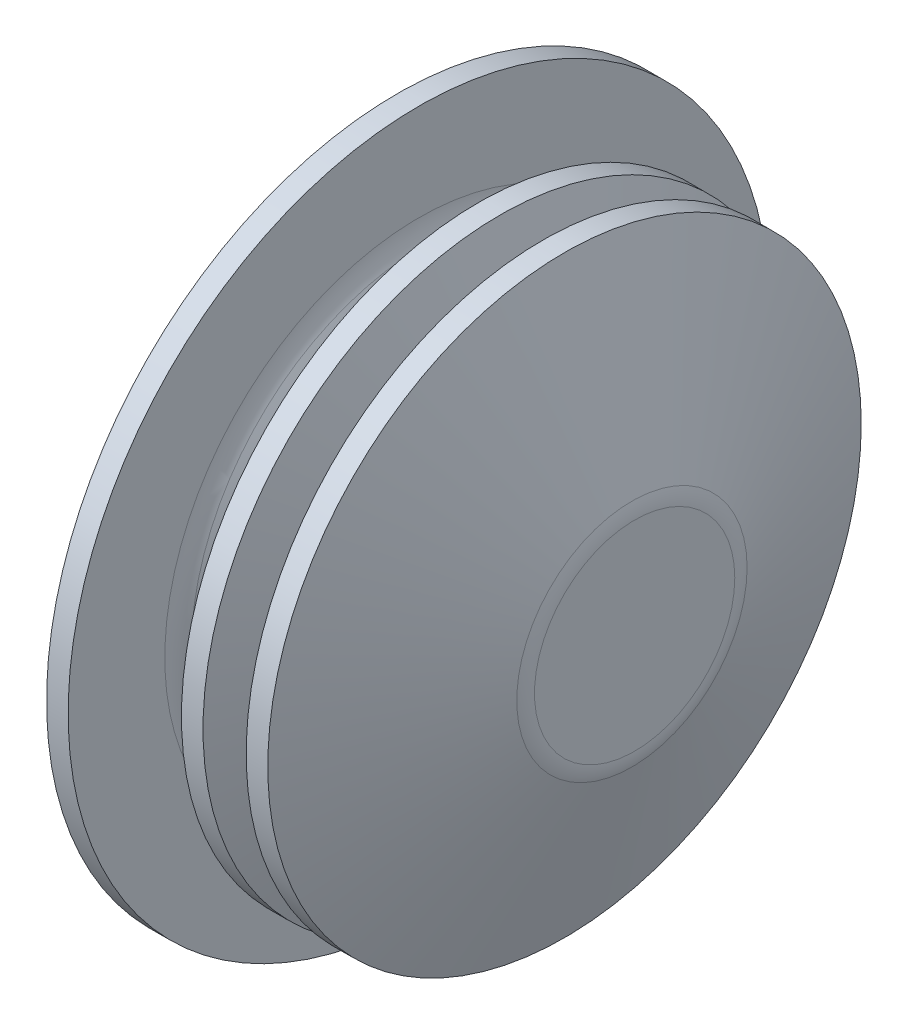
from build123d import *


with BuildPart() as part:
    # Sketch2 → Revolve1 (revolve)
    with BuildSketch(Plane(origin=(0, 0, 0), x_dir=(1, 0, 0), z_dir=(0, 1, 0))):
        with BuildLine():
            Line((0, 0), (0, 13))
            Line((0, 13), (0.8, 13))
            Line((0.8, 13), (0.8, 9.417496864))
            ThreePointArc((0.8, 9.417496864), (0.851837315, 9.013526198), (1.003990374, 8.635731474))
            Line((1.003990374, 8.635731474), (3.141788619, 4.81823461))
            ThreePointArc((3.141788619, 4.81823461), (3.728732309, 4.219633269), (4.537798244, 4))
            Line((4.537798244, 4), (5.168545919, 4))
            ThreePointArc((5.168545919, 4), (5.414855468, 4.128735275), (5.449773501, 4.404455959))
            Line((5.449773501, 4.404455959), (3, 11))
            Line((3, 11), (3.8, 11))
            Line((3.8, 11), (6.012636566, 5.042901553))
            ThreePointArc((6.012636566, 5.042901553), (6.599105133, 4.286349073), (7.512517001, 4))
            Line((7.512517001, 4), (7.568545919, 4))
            ThreePointArc((7.568545919, 4), (7.814855468, 4.128735275), (7.849773501, 4.404455959))
            Line((7.849773501, 4.404455959), (5.4, 11))
            Line((5.4, 11), (6.2, 11))
            Line((6.2, 11), (8.699880435, 4.269552674))
            ThreePointArc((8.699880435, 4.269552674), (8.774771205, 3.995465979), (8.8, 3.712454227))
            Line((8.8, 3.712454227), (8.8, 0))
            Line((8.8, 0), (0, 0))
        make_face()
    revolve(axis=Axis((8.8, 0, 0), (-1, 0, 0)))


solid = part.part
